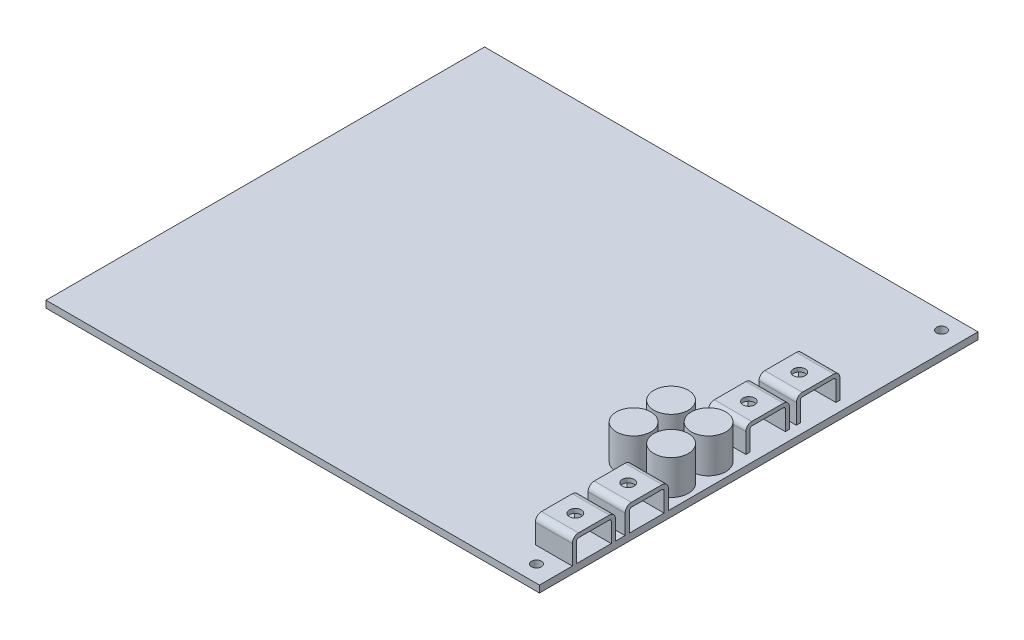
from build123d import *

# Parameters (mm, degrees)
SKETCH1_W           = 127
SKETCH1_H           = 112.8776
BOSS_EXTRUDE1_DEPTH = 1.778
SKETCH2_R           = 1.27
CUT_EXTRUDE1_DEPTH  = 1.778
BOSS_EXTRUDE2_DEPTH = 9.525
SKETCH4_R           = 1.524
CUT_EXTRUDE2_DEPTH  = 1.0922
LPATTERN1_COUNT     = 2
LPATTERN1_PITCH     = 13.589
BOSS_EXTRUDE3_DEPTH = 9.652
SKETCH6_R           = 1.524
CUT_EXTRUDE3_DEPTH  = 1.016
FILLET1_R           = 1.524
FILLET2_R           = 0.508
LPATTERN2_COUNT     = 2
LPATTERN2_PITCH     = 13.0048
SKETCH7_R           = 1.524
CUT_EXTRUDE4_DEPTH  = 1.016
FILLET3_R           = 0.508
FILLET4_R           = 1.524
SKETCH8_R           = 4.445
BOSS_EXTRUDE4_DEPTH = 8.89


with BuildPart() as part:
    # Sketch1 → Boss-Extrude1 (new body)
    with BuildSketch(Plane(origin=(0, 0, 0), x_dir=(1, 0, 0), z_dir=(0, 1, 0))):
        Rectangle(SKETCH1_W, SKETCH1_H)
    extrude(amount=BOSS_EXTRUDE1_DEPTH)

    # Sketch2 → Cut-Extrude1 (cut)
    with BuildSketch(Plane(origin=(0, 1.778, 0), x_dir=(1, 0, 0), z_dir=(0, 1, 0))):
        with Locations((58.42, 52.1208)):
            Circle(SKETCH2_R)
        with Locations((58.42, -52.1208)):
            Circle(SKETCH2_R)
    extrude(amount=-CUT_EXTRUDE1_DEPTH, mode=Mode.SUBTRACT)

    # Sketch3 → Boss-Extrude2 (add)
    with BuildSketch(Plane(origin=(63.5, 0, 0), x_dir=(0, 0, -1), z_dir=(1, 0, 0))):
        with BuildLine():
            Line((-46.8884, 1.778), (-46.8884, 6.7818))
            ThreePointArc((-46.8884, 6.7818), (-46.739610245, 7.141010245), (-46.3804, 7.2898))
            Line((-46.3804, 7.2898), (-38.4556, 7.2898))
            ThreePointArc((-38.4556, 7.2898), (-38.096389755, 7.141010245), (-37.9476, 6.7818))
            Line((-37.9476, 6.7818), (-37.9476, 1.778))
            Line((-37.9476, 1.778), (-36.8554, 1.778))
            Line((-36.8554, 1.778), (-36.8554, 6.7818))
            ThreePointArc((-36.8554, 6.7818), (-37.324087729, 7.913312271), (-38.4556, 8.382))
            Line((-38.4556, 8.382), (-46.3804, 8.382))
            ThreePointArc((-46.3804, 8.382), (-47.511912271, 7.913312271), (-47.9806, 6.7818))
            Line((-47.9806, 6.7818), (-47.9806, 1.778))
            Line((-47.9806, 1.778), (-46.8884, 1.778))
        make_face()
    boss_extrude2 = extrude(amount=-BOSS_EXTRUDE2_DEPTH)

    # Sketch4 → Cut-Extrude2 (cut)
    with BuildSketch(Plane(origin=(0, 8.382, 0), x_dir=(1, 0, 0), z_dir=(0, 1, 0))):
        with Locations((58.7375, -42.418)):
            Circle(SKETCH4_R)
    cut_extrude2 = extrude(amount=-CUT_EXTRUDE2_DEPTH, mode=Mode.SUBTRACT)

    # LPattern1: Boss-Extrude2, Cut-Extrude2 ×2
    with Locations(*[(0, 0, -i * LPATTERN1_PITCH) for i in range(1, LPATTERN1_COUNT)]):
        add(boss_extrude2)
        add(cut_extrude2, mode=Mode.SUBTRACT)

    # Sketch5 → Boss-Extrude3 (add)
    with BuildSketch(Plane(origin=(60.96, 0, 0), x_dir=(0, 0, -1), z_dir=(1, 0, 0))):
        Polygon((23.4188, 1.778), (23.4188, 8.382), (12.2428, 8.382), (12.2428, 1.778), (13.2588, 1.778), (13.2588, 7.366), (22.4028, 7.366), (22.4028, 1.778), align=None)
    boss_extrude3 = extrude(amount=-BOSS_EXTRUDE3_DEPTH)

    # Sketch6 → Cut-Extrude3 (cut)
    with BuildSketch(Plane(origin=(0, 8.382, 0), x_dir=(1, 0, 0), z_dir=(0, 1, 0))):
        with Locations((56.134, 17.8308)):
            Circle(SKETCH6_R)
    extrude(amount=-CUT_EXTRUDE3_DEPTH, mode=Mode.SUBTRACT)

    # Fillet1
    fillet1_edges = [part.edges().sort_by_distance(p)[0] for p in [
        (56.134, 8.382, -12.2428),
        (56.134, 8.382, -23.4188),
    ]]
    fillet(fillet1_edges, radius=FILLET1_R)

    # Fillet2
    fillet2_edges = [part.edges().sort_by_distance(p)[0] for p in [
        (56.134, 7.366, -22.4028),
        (56.134, 7.366, -13.2588),
    ]]
    fillet(fillet2_edges, radius=FILLET2_R)

    # LPattern2: Boss-Extrude3 ×2
    with Locations(*[(0, 0, i * LPATTERN2_PITCH) for i in range(1, LPATTERN2_COUNT)]):
        add(boss_extrude3)

    # Sketch7 → Cut-Extrude4 (cut)
    with BuildSketch(Plane(origin=(0, 8.382, 0), x_dir=(1, 0, 0), z_dir=(0, 1, 0))):
        with Locations((56.134, 4.826)):
            Circle(SKETCH7_R)
    extrude(amount=-CUT_EXTRUDE4_DEPTH, mode=Mode.SUBTRACT)

    # Fillet3
    fillet3_edges = [part.edges().sort_by_distance(p)[0] for p in [
        (56.134, 7.366, -9.398),
        (56.134, 7.366, -0.254),
    ]]
    fillet(fillet3_edges, radius=FILLET3_R)

    # Fillet4
    fillet4_edges = [part.edges().sort_by_distance(p)[0] for p in [
        (56.134, 8.382, 0.762),
        (56.134, 8.382, -10.414),
    ]]
    fillet(fillet4_edges, radius=FILLET4_R)

    # Sketch8 → Boss-Extrude4 (add)
    with BuildSketch(Plane(origin=(0, 1.778, 0), x_dir=(1, 0, 0), z_dir=(0, 1, 0))):
        with Locations((57.785, -7.1882)):
            Circle(SKETCH8_R)
        with Locations((57.785, -16.8402)):
            Circle(SKETCH8_R)
        with Locations((48.133, -7.1882)):
            Circle(SKETCH8_R)
        with Locations((48.133, -16.8402)):
            Circle(SKETCH8_R)
    extrude(amount=BOSS_EXTRUDE4_DEPTH)


solid = part.part
